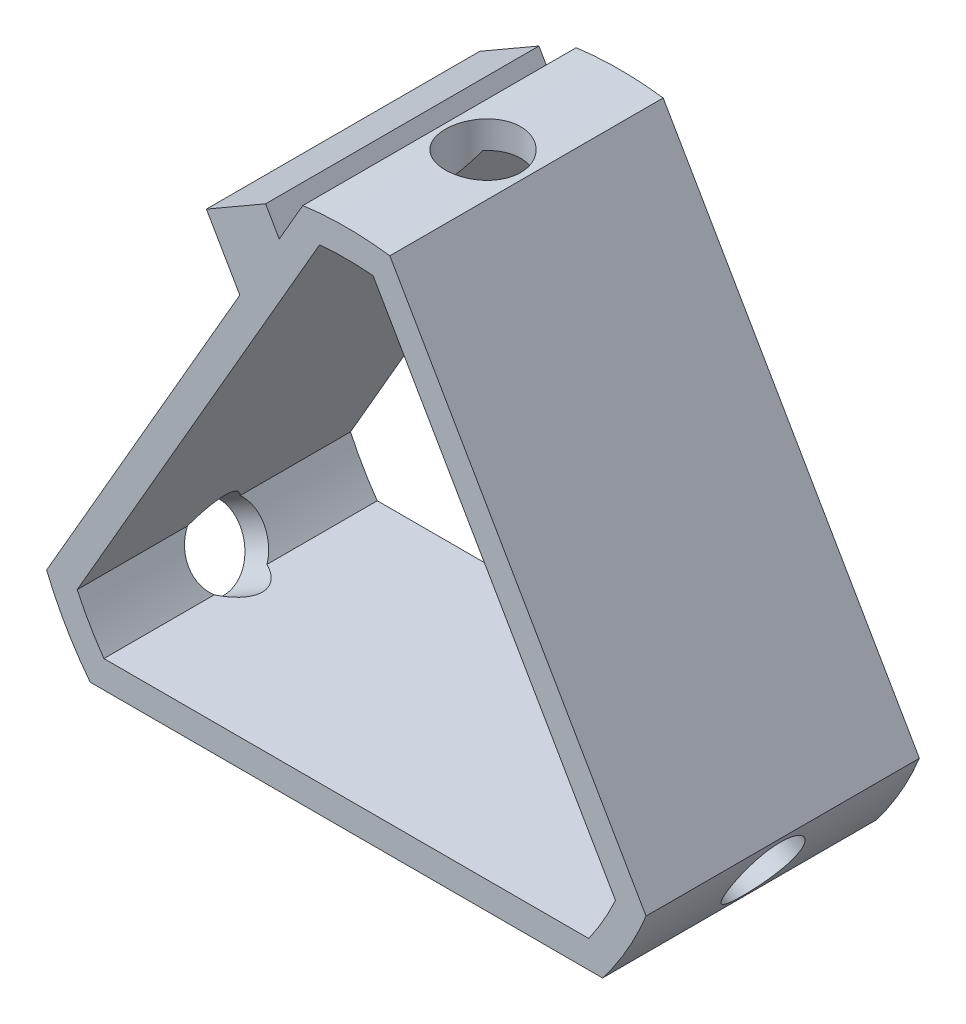
from build123d import *

# Parameters (mm, degrees)
BOSS_EXTRU_1_DEPTH      = 10
ESQUISSE2_R             = 2.75
ENL_V_MAT_EXTRU_1_DEPTH = 10
ESQUISSE3_R             = 2.75
ENL_V_MAT_EXTRU_2_DEPTH = 10
ESQUISSE4_R             = 2.75
ENL_V_MAT_EXTRU_3_DEPTH = 10
BOSS_EXTRU_4_DEPTH      = 20


with BuildPart() as part:
    # Esquisse1 → Boss.-Extru.1 (new body, symmetric)
    with BuildSketch(Plane.XY):
        with BuildLine():
            ThreePointArc((-3.184001831, 23.485147058), (0, 23.7), (3.184001831, 23.485147058))
            Line((3.184001831, 23.485147058), (21.930734879, -8.985147058))
            ThreePointArc((21.930734879, -8.985147058), (20.52480207, -11.85), (18.746733049, -14.5))
            Line((18.746733049, -14.5), (-18.746733049, -14.5))
            ThreePointArc((-18.746733049, -14.5), (-20.52480207, -11.85), (-21.930734879, -8.985147058))
            Line((-21.930734879, -8.985147058), (-3.184001831, 23.485147058))
        make_face()
        with BuildLine():
            ThreePointArc((17.738094599, -12.5), (18.792751262, -10.85), (19.694364847, -9.111640537))
            Line((19.694364847, -9.111640537), (1.956270248, 21.611640537))
            ThreePointArc((1.956270248, 21.611640537), (0, 21.7), (-1.956270248, 21.611640537))
            Line((-1.956270248, 21.611640537), (-19.694364847, -9.111640537))
            ThreePointArc((-19.694364847, -9.111640537), (-18.792751262, -10.85), (-17.738094599, -12.5))
            Line((-17.738094599, -12.5), (17.738094599, -12.5))
        make_face(mode=Mode.SUBTRACT)
    extrude(amount=BOSS_EXTRU_1_DEPTH, both=True)

    # Esquisse2 → Enlèv. mat.-Extru.1 (cut, symmetric)
    with BuildSketch(Plane(origin=(20.338733964, -11.742573529, 0), x_dir=(0, 0, 1), z_dir=(-0.866025404, 0.5, 0))):
        Circle(ESQUISSE2_R)
    extrude(amount=ENL_V_MAT_EXTRU_1_DEPTH, both=True, mode=Mode.SUBTRACT)

    # Esquisse3 → Enlèv. mat.-Extru.2 (cut, symmetric)
    with BuildSketch(Plane(origin=(-20.338733964, -11.742573529, 0), x_dir=(0, 0, 1), z_dir=(-0.866025404, -0.5, 0))):
        Circle(ESQUISSE3_R)
    extrude(amount=ENL_V_MAT_EXTRU_2_DEPTH, both=True, mode=Mode.SUBTRACT)

    # Esquisse4 → Enlèv. mat.-Extru.3 (cut, symmetric)
    with BuildSketch(Plane(origin=(0, 23.485147058, 0), x_dir=(-1, 0, 0), z_dir=(0, -1, 0))):
        Circle(ESQUISSE4_R)
    extrude(amount=ENL_V_MAT_EXTRU_3_DEPTH, both=True, mode=Mode.SUBTRACT)

    # Esquisse6 → Boss.-Extru.4 (add)
    with BuildSketch(Plane(origin=(0, 0, -10), x_dir=(-1, 0, 0), z_dir=(0, 0, -1))):
        Polygon((4.907477288, 20.5), (5.907477288, 22.232050808), (10.237604307, 19.732050808), (7.794228634, 15.5), align=None)
    extrude(amount=-BOSS_EXTRU_4_DEPTH)


solid = part.part
